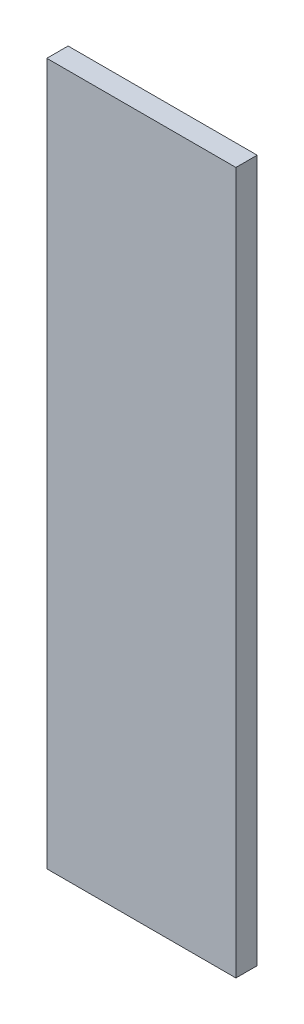
from build123d import *

# Parameters (mm, degrees)
SKETCH1_W           = 160
SKETCH1_H           = 594
BOSS_EXTRUDE1_DEPTH = 18


with BuildPart() as part:
    # Sketch1 → Boss-Extrude1 (new body)
    with BuildSketch(Plane.XY):
        Rectangle(SKETCH1_W, SKETCH1_H)
    extrude(amount=BOSS_EXTRUDE1_DEPTH)


solid = part.part
